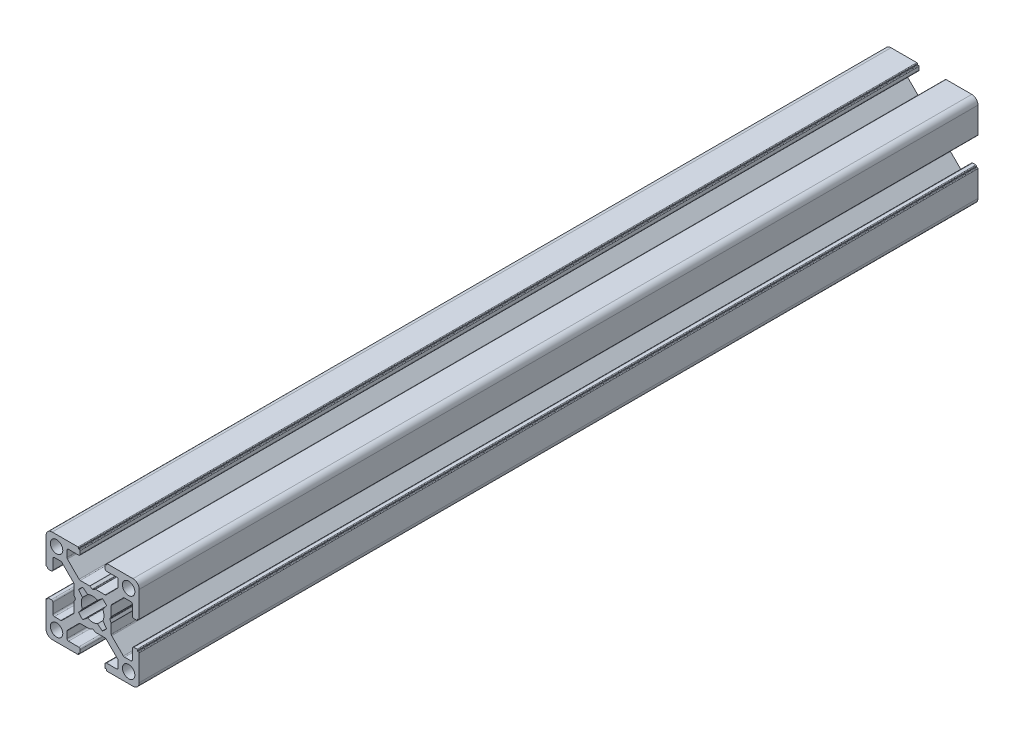
from build123d import *

# Parameters (mm, degrees)
CROQUIS1_R              = 2
SALIENTE_EXTRUIR1_DEPTH = 270


with BuildPart() as part:
    # Croquis1 → Saliente-Extruir1 (new body)
    with BuildSketch(Plane.XY.offset(1000)):
        with BuildLine():
            Line((9.800000436, -10.500000436), (10.100000436, -10.500000436))
            ThreePointArc((10.100000436, -10.500000436), (10.241421792, -10.441421792), (10.300000436, -10.300000436))
            Line((10.300000436, -10.300000436), (10.300000436, -2))
            ThreePointArc((10.300000436, -2), (9.714213998, -0.585786438), (8.300000436, 0))
            Line((8.300000436, 0), (0, 0))
            ThreePointArc((0, 0), (-0.141421356, -0.058578644), (-0.2, -0.2))
            Line((-0.2, -0.2), (-0.2, -0.5))
            Line((-0.2, -0.5), (-0.49999919, -0.5))
            ThreePointArc((-0.49999919, -0.5), (-0.641420811, -0.558578753), (-0.699999564, -0.700000374))
            Line((-0.699999564, -0.700000374), (-0.699999564, -1.700000763))
            ThreePointArc((-0.699999564, -1.700000763), (-0.553552955, -2.053554154), (-0.199999564, -2.200000763))
            Line((-0.199999564, -2.200000763), (3.050000763, -2.200000763))
            ThreePointArc((3.050000763, -2.200000763), (3.403554154, -2.346447372), (3.550000763, -2.700000763))
            Line((3.550000763, -2.700000763), (3.550000763, -4.743055509))
            ThreePointArc((3.550000763, -4.743055509), (3.511993279, -4.934269826), (3.403749103, -5.096413843))
            Line((3.403749103, -5.096413843), (-0.349053376, -8.853358334))
            ThreePointArc((-0.349053376, -8.853358334), (-0.511332616, -8.961886981), (-0.702801716, -9))
            Line((-0.702801716, -9), (-3.746809419, -9))
            ThreePointArc((-3.746809419, -9), (-3.798212795, -9.006718618), (-3.846162576, -9.026423071))
            Line((-3.846162576, -9.026423071), (-4.600646407, -9.458279719))
            ThreePointArc((-4.600646407, -9.458279719), (-4.699999564, -9.48470279), (-4.799352721, -9.458279719))
            Line((-4.799352721, -9.458279719), (-5.553836552, -9.026423071))
            ThreePointArc((-5.553836552, -9.026423071), (-5.601786333, -9.006718618), (-5.653189709, -9))
            Line((-5.653189709, -9), (-8.697197412, -9))
            ThreePointArc((-8.697197412, -9), (-8.888666513, -8.961886981), (-9.050945752, -8.853358334))
            Line((-9.050945752, -8.853358334), (-12.803748231, -5.096413843))
            ThreePointArc((-12.803748231, -5.096413843), (-12.911992407, -4.934269826), (-12.949999891, -4.743055509))
            Line((-12.949999891, -4.743055509), (-12.949999891, -2.700000763))
            ThreePointArc((-12.949999891, -2.700000763), (-12.803553282, -2.346447372), (-12.449999891, -2.200000763))
            Line((-12.449999891, -2.200000763), (-9.199999564, -2.200000763))
            ThreePointArc((-9.199999564, -2.200000763), (-8.846446173, -2.053554154), (-8.699999564, -1.700000763))
            Line((-8.699999564, -1.700000763), (-8.699999564, -0.700000374))
            ThreePointArc((-8.699999564, -0.700000374), (-8.758578317, -0.558578753), (-8.899999938, -0.5))
            Line((-8.899999938, -0.5), (-9.199999128, -0.5))
            Line((-9.199999128, -0.5), (-9.199999128, -0.2))
            ThreePointArc((-9.199999128, -0.2), (-9.258577772, -0.058578644), (-9.399999128, 0))
            Line((-9.399999128, 0), (-17.699999564, 0))
            ThreePointArc((-17.699999564, 0), (-19.114213126, -0.585786438), (-19.699999564, -2))
            Line((-19.699999564, -2), (-19.699999564, -10.300000436))
            ThreePointArc((-19.699999564, -10.300000436), (-19.64142092, -10.441421792), (-19.499999564, -10.500000436))
            Line((-19.499999564, -10.500000436), (-19.199999564, -10.500000436))
            Line((-19.199999564, -10.500000436), (-19.199999564, -10.799999627))
            ThreePointArc((-19.199999564, -10.799999627), (-19.141420811, -10.941421247), (-18.99999919, -11))
            Line((-18.99999919, -11), (-17.999998801, -11))
            ThreePointArc((-17.999998801, -11), (-17.64644541, -10.853553391), (-17.499998801, -10.5))
            Line((-17.499998801, -10.5), (-17.499998801, -7.249999673))
            ThreePointArc((-17.499998801, -7.249999673), (-17.353552192, -6.896446283), (-16.999998801, -6.749999673))
            Line((-16.999998801, -6.749999673), (-14.956944055, -6.749999673))
            ThreePointArc((-14.956944055, -6.749999673), (-14.765729738, -6.788007157), (-14.603585721, -6.896251334))
            Line((-14.603585721, -6.896251334), (-10.84664123, -10.649053813))
            ThreePointArc((-10.84664123, -10.649053813), (-10.738112583, -10.811333052), (-10.699999564, -11.002802152))
            Line((-10.699999564, -11.002802152), (-10.699999564, -14.046809855))
            ThreePointArc((-10.699999564, -14.046809855), (-10.693280947, -14.098213232), (-10.673576493, -14.146163012))
            Line((-10.673576493, -14.146163012), (-10.241719845, -14.900646843))
            ThreePointArc((-10.241719845, -14.900646843), (-10.215296774, -15), (-10.241719845, -15.099353157))
            Line((-10.241719845, -15.099353157), (-10.673576493, -15.853836988))
            ThreePointArc((-10.673576493, -15.853836988), (-10.693280947, -15.901786769), (-10.699999564, -15.953190146))
            Line((-10.699999564, -15.953190146), (-10.699999564, -18.997197848))
            ThreePointArc((-10.699999564, -18.997197848), (-10.738112583, -19.188666949), (-10.84664123, -19.350946188))
            Line((-10.84664123, -19.350946188), (-14.603585721, -23.103748667))
            ThreePointArc((-14.603585721, -23.103748667), (-14.765729738, -23.211992843), (-14.956944055, -23.250000327))
            Line((-14.956944055, -23.250000327), (-16.999998801, -23.250000327))
            ThreePointArc((-16.999998801, -23.250000327), (-17.353552192, -23.103553718), (-17.499998801, -22.750000327))
            Line((-17.499998801, -22.750000327), (-17.499998801, -19.5))
            ThreePointArc((-17.499998801, -19.5), (-17.64644541, -19.14644661), (-17.999998801, -19))
            Line((-17.999998801, -19), (-18.99999919, -19))
            ThreePointArc((-18.99999919, -19), (-19.141420811, -19.058578753), (-19.199999564, -19.200000374))
            Line((-19.199999564, -19.200000374), (-19.199999564, -19.499999564))
            Line((-19.199999564, -19.499999564), (-19.499999564, -19.499999564))
            ThreePointArc((-19.499999564, -19.499999564), (-19.64142092, -19.558578208), (-19.699999564, -19.699999564))
            Line((-19.699999564, -19.699999564), (-19.699999564, -28))
            ThreePointArc((-19.699999564, -28), (-19.114213126, -29.414213563), (-17.699999564, -30))
            Line((-17.699999564, -30), (-9.399999128, -30))
            ThreePointArc((-9.399999128, -30), (-9.258577772, -29.941421356), (-9.199999128, -29.8))
            Line((-9.199999128, -29.8), (-9.199999128, -29.5))
            Line((-9.199999128, -29.5), (-8.899999938, -29.5))
            ThreePointArc((-8.899999938, -29.5), (-8.758578317, -29.441421247), (-8.699999564, -29.299999627))
            Line((-8.699999564, -29.299999627), (-8.699999564, -28.299999237))
            ThreePointArc((-8.699999564, -28.299999237), (-8.846446173, -27.946445847), (-9.199999564, -27.799999237))
            Line((-9.199999564, -27.799999237), (-12.449999891, -27.799999237))
            ThreePointArc((-12.449999891, -27.799999237), (-12.803553282, -27.653552628), (-12.949999891, -27.299999237))
            Line((-12.949999891, -27.299999237), (-12.949999891, -25.256944491))
            ThreePointArc((-12.949999891, -25.256944491), (-12.911992407, -25.065730174), (-12.803748231, -24.903586157))
            Line((-12.803748231, -24.903586157), (-9.050945752, -21.146641666))
            ThreePointArc((-9.050945752, -21.146641666), (-8.888666513, -21.038113019), (-8.697197412, -21))
            Line((-8.697197412, -21), (-5.653189709, -21))
            ThreePointArc((-5.653189709, -21), (-5.601786333, -20.993281383), (-5.553836552, -20.973576929))
            Line((-5.553836552, -20.973576929), (-4.799352721, -20.541720281))
            ThreePointArc((-4.799352721, -20.541720281), (-4.699999564, -20.51529721), (-4.600646407, -20.541720281))
            Line((-4.600646407, -20.541720281), (-3.846162576, -20.973576929))
            ThreePointArc((-3.846162576, -20.973576929), (-3.798212795, -20.993281383), (-3.746809419, -21))
            Line((-3.746809419, -21), (-0.702801716, -21))
            ThreePointArc((-0.702801716, -21), (-0.511332616, -21.038113019), (-0.349053377, -21.146641666))
            Line((-0.349053377, -21.146641666), (3.403749103, -24.903586157))
            ThreePointArc((3.403749103, -24.903586157), (3.511993279, -25.065730174), (3.550000763, -25.256944491))
            Line((3.550000763, -25.256944491), (3.550000763, -27.299999237))
            ThreePointArc((3.550000763, -27.299999237), (3.403554154, -27.653552628), (3.050000763, -27.799999237))
            Line((3.050000763, -27.799999237), (-0.199999564, -27.799999237))
            ThreePointArc((-0.199999564, -27.799999237), (-0.553552955, -27.946445847), (-0.699999564, -28.299999237))
            Line((-0.699999564, -28.299999237), (-0.699999564, -29.299999627))
            ThreePointArc((-0.699999564, -29.299999627), (-0.641420811, -29.441421247), (-0.49999919, -29.5))
            Line((-0.49999919, -29.5), (-0.2, -29.5))
            Line((-0.2, -29.5), (-0.2, -29.8))
            ThreePointArc((-0.2, -29.8), (-0.141421356, -29.941421356), (0, -30))
            Line((0, -30), (8.300000436, -30))
            ThreePointArc((8.300000436, -30), (9.714213998, -29.414213563), (10.300000436, -28))
            Line((10.300000436, -28), (10.300000436, -19.699999564))
            ThreePointArc((10.300000436, -19.699999564), (10.241421792, -19.558578208), (10.100000436, -19.499999564))
            Line((10.100000436, -19.499999564), (9.800000436, -19.499999564))
            Line((9.800000436, -19.499999564), (9.800000436, -19.200000374))
            ThreePointArc((9.800000436, -19.200000374), (9.741421683, -19.058578753), (9.600000062, -19))
            Line((9.600000062, -19), (8.599999673, -19))
            ThreePointArc((8.599999673, -19), (8.246446283, -19.14644661), (8.099999673, -19.5))
            Line((8.099999673, -19.5), (8.099999673, -22.750000327))
            ThreePointArc((8.099999673, -22.750000327), (7.953553064, -23.103553718), (7.599999673, -23.250000327))
            Line((7.599999673, -23.250000327), (5.556944927, -23.250000327))
            ThreePointArc((5.556944927, -23.250000327), (5.36573061, -23.211992843), (5.203586593, -23.103748667))
            Line((5.203586593, -23.103748667), (1.446642102, -19.350946188))
            ThreePointArc((1.446642102, -19.350946188), (1.338113455, -19.188666949), (1.300000436, -18.997197848))
            Line((1.300000436, -18.997197848), (1.300000436, -15.953190145))
            ThreePointArc((1.300000436, -15.953190145), (1.293281819, -15.901786769), (1.273577365, -15.853836988))
            Line((1.273577365, -15.853836988), (0.841720717, -15.099353157))
            ThreePointArc((0.841720717, -15.099353157), (0.815297646, -15), (0.841720717, -14.900646843))
            Line((0.841720717, -14.900646843), (1.273577365, -14.146163012))
            ThreePointArc((1.273577365, -14.146163012), (1.293281819, -14.098213231), (1.300000436, -14.046809855))
            Line((1.300000436, -14.046809855), (1.300000436, -11.002802152))
            ThreePointArc((1.300000436, -11.002802152), (1.338113455, -10.811333052), (1.446642102, -10.649053813))
            Line((1.446642102, -10.649053813), (5.203586593, -6.896251334))
            ThreePointArc((5.203586593, -6.896251334), (5.36573061, -6.788007157), (5.556944927, -6.749999673))
            Line((5.556944927, -6.749999673), (7.599999673, -6.749999673))
            ThreePointArc((7.599999673, -6.749999673), (7.953553064, -6.896446283), (8.099999673, -7.249999673))
            Line((8.099999673, -7.249999673), (8.099999673, -10.5))
            ThreePointArc((8.099999673, -10.5), (8.246446283, -10.853553391), (8.599999673, -11))
            Line((8.599999673, -11), (9.600000062, -11))
            ThreePointArc((9.600000062, -11), (9.741421683, -10.941421247), (9.800000436, -10.799999627))
            Line((9.800000436, -10.799999627), (9.800000436, -10.500000436))
        make_face()
        with Locations((-16.300000272, -3.399999983)):
            Circle(CROQUIS1_R, mode=Mode.SUBTRACT)
        with Locations((6.900001145, -3.399999983)):
            Circle(CROQUIS1_R, mode=Mode.SUBTRACT)
        with Locations((-16.300000272, -26.600000017)):
            Circle(CROQUIS1_R, mode=Mode.SUBTRACT)
        with Locations((6.900001145, -26.600000017)):
            Circle(CROQUIS1_R, mode=Mode.SUBTRACT)
        with BuildLine():
            Line((-7.835928976, -10.481599097), (-6.300129088, -11.719438233))
            ThreePointArc((-6.300129088, -11.719438233), (-4.699999564, -11.35), (-3.09987004, -11.719438233))
            Line((-3.09987004, -11.719438233), (-1.564070152, -10.481599097))
            ThreePointArc((-1.564070152, -10.481599097), (-0.818997305, -11.10284444), (-0.194662672, -11.845330527))
            Line((-0.194662672, -11.845330527), (-1.419437832, -13.399870404))
            ThreePointArc((-1.419437832, -13.399870404), (-1.049999564, -15), (-1.419437832, -16.600129597))
            Line((-1.419437832, -16.600129597), (-0.194662672, -18.154669473))
            ThreePointArc((-0.194662672, -18.154669473), (-0.818997305, -18.897155561), (-1.564070152, -19.518400903))
            Line((-1.564070152, -19.518400903), (-3.09987004, -18.280561767))
            ThreePointArc((-3.09987004, -18.280561767), (-4.699999564, -18.65), (-6.300129088, -18.280561767))
            Line((-6.300129088, -18.280561767), (-7.835928976, -19.518400903))
            ThreePointArc((-7.835928976, -19.518400903), (-8.581001823, -18.897155561), (-9.205336456, -18.154669473))
            Line((-9.205336456, -18.154669473), (-7.980561295, -16.600129597))
            ThreePointArc((-7.980561295, -16.600129597), (-8.349999564, -15), (-7.980561296, -13.399870404))
            Line((-7.980561296, -13.399870404), (-9.205336456, -11.845330527))
            ThreePointArc((-9.205336456, -11.845330527), (-8.581001823, -11.10284444), (-7.835928976, -10.481599097))
        make_face(mode=Mode.SUBTRACT)
    extrude(amount=-SALIENTE_EXTRUIR1_DEPTH)


solid = part.part
